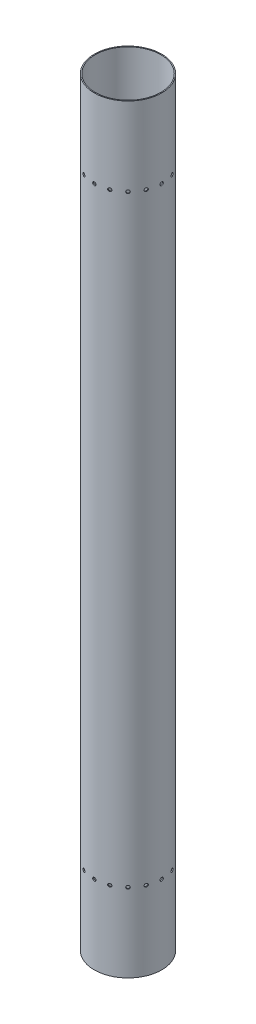
from build123d import *

# Parameters (mm, degrees)
SKETCH1_R                     = 65.405
SKETCH1_R_2                   = 63.5
BOSS_EXTRUDE1_DEPTH           = 1473.2
ENGINE_START                  = -1.984425
SKETCH2_R                     = 3.175
ENGINE_ATTACHMENT_HOLES_DEPTH = 1.984425
CIRPATTERN1_COUNT             = 16
RECOVERY_START                = -1.984425
SKETCH3_R                     = 3.175
RECOVERY_PLATE_HOLES_DEPTH    = 1.984425
CIRPATTERN2_COUNT             = 16


with BuildPart() as part:
    # Sketch1 → Boss-Extrude1 (new body)
    with BuildSketch(Plane(origin=(0, 0, 0), x_dir=(1, 0, 0), z_dir=(0, 1, 0))):
        Circle(SKETCH1_R)
        Circle(SKETCH1_R_2, mode=Mode.SUBTRACT)
    extrude(amount=-BOSS_EXTRUDE1_DEPTH)

    # Sketch2 → Engine Attachment Holes (cut)
    with BuildSketch(Plane.XY.offset(65.405).offset(ENGINE_START)):
        with Locations((0, -1320.8)):
            Circle(SKETCH2_R)
    engine_attachment_holes = extrude(amount=ENGINE_ATTACHMENT_HOLES_DEPTH, mode=Mode.SUBTRACT)

    # CirPattern1: Engine Attachment Holes ×16 about axis
    cirpattern1_axis = Axis((0, -1473.2, 0), (0, 1, 0))
    for i in range(1, CIRPATTERN1_COUNT):
        add(engine_attachment_holes.rotate(cirpattern1_axis, i * 360 / CIRPATTERN1_COUNT), mode=Mode.SUBTRACT)

    # Sketch3 → Recovery Plate Holes (cut)
    with BuildSketch(Plane.XY.offset(65.405).offset(RECOVERY_START)):
        with Locations((0, -152.4)):
            Circle(SKETCH3_R)
    recovery_plate_holes = extrude(amount=RECOVERY_PLATE_HOLES_DEPTH, mode=Mode.SUBTRACT)

    # CirPattern2: Recovery Plate Holes ×16 about axis
    cirpattern2_axis = Axis((0, 0, 0), (0, 1, 0))
    for i in range(1, CIRPATTERN2_COUNT):
        add(recovery_plate_holes.rotate(cirpattern2_axis, i * 360 / CIRPATTERN2_COUNT), mode=Mode.SUBTRACT)


solid = part.part
